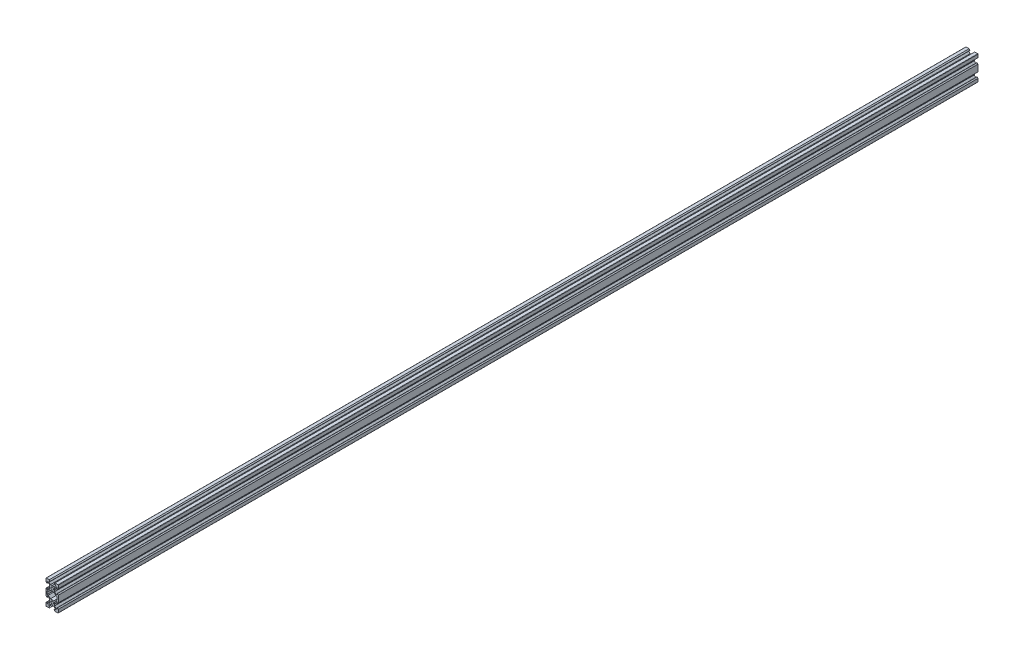
from build123d import *

# Parameters (mm, degrees)
SKETCH1_R           = 2.1
BOSS_EXTRUDE1_DEPTH = 1500


with BuildPart() as part:
    # Sketch1 → Boss-Extrude1 (new body)
    with BuildSketch(Plane.XY):
        with BuildLine():
            Line((4.58, -20), (9.5, -20))
            ThreePointArc((9.5, -20), (9.853553391, -19.853553391), (10, -19.5))
            Line((10, -19.5), (10, -14.58))
            Line((10, -14.58), (8.545, -13.125))
            Line((8.545, -13.125), (8.2, -13.125))
            Line((8.2, -13.125), (8.2, -15.5))
            Line((8.2, -15.5), (6.560660172, -15.5))
            Line((6.560660172, -15.5), (3.9, -12.839339828))
            Line((3.9, -12.839339828), (3.9, -10.21))
            Line((3.9, -10.21), (3.69, -10))
            Line((3.69, -10), (3.9, -9.79))
            Line((3.9, -9.79), (3.9, -7.160660172))
            Line((3.9, -7.160660172), (6.560660172, -4.5))
            Line((6.560660172, -4.5), (8.2, -4.5))
            Line((8.2, -4.5), (8.2, -6.875))
            Line((8.2, -6.875), (8.545, -6.875))
            Line((8.545, -6.875), (10, -5.42))
            Line((10, -5.42), (10, 5.42))
            Line((10, 5.42), (8.545, 6.875))
            Line((8.545, 6.875), (8.2, 6.875))
            Line((8.2, 6.875), (8.2, 4.5))
            Line((8.2, 4.5), (6.560660172, 4.5))
            Line((6.560660172, 4.5), (3.9, 7.160660172))
            Line((3.9, 7.160660172), (3.9, 9.79))
            Line((3.9, 9.79), (3.69, 10))
            Line((3.69, 10), (3.9, 10.21))
            Line((3.9, 10.21), (3.9, 12.839339828))
            Line((3.9, 12.839339828), (6.560660172, 15.5))
            Line((6.560660172, 15.5), (8.2, 15.5))
            Line((8.2, 15.5), (8.2, 13.125))
            Line((8.2, 13.125), (8.545, 13.125))
            Line((8.545, 13.125), (10, 14.58))
            Line((10, 14.58), (10, 19.5))
            ThreePointArc((10, 19.5), (9.853553391, 19.853553391), (9.5, 20))
            Line((9.5, 20), (4.58, 20))
            Line((4.58, 20), (3.125, 18.545))
            Line((3.125, 18.545), (3.125, 18.2))
            Line((3.125, 18.2), (5.5, 18.2))
            Line((5.5, 18.2), (5.5, 16.560660172))
            Line((5.5, 16.560660172), (2.839339828, 13.9))
            Line((2.839339828, 13.9), (0.21, 13.9))
            Line((0.21, 13.9), (0, 13.69))
            Line((0, 13.69), (-0.21, 13.9))
            Line((-0.21, 13.9), (-2.839339828, 13.9))
            Line((-2.839339828, 13.9), (-5.5, 16.560660172))
            Line((-5.5, 16.560660172), (-5.5, 18.2))
            Line((-5.5, 18.2), (-3.125, 18.2))
            Line((-3.125, 18.2), (-3.125, 18.545))
            Line((-3.125, 18.545), (-4.58, 20))
            Line((-4.58, 20), (-9.5, 20))
            ThreePointArc((-9.5, 20), (-9.853553391, 19.853553391), (-10, 19.5))
            Line((-10, 19.5), (-10, 14.58))
            Line((-10, 14.58), (-8.545, 13.125))
            Line((-8.545, 13.125), (-8.2, 13.125))
            Line((-8.2, 13.125), (-8.2, 15.5))
            Line((-8.2, 15.5), (-6.560660172, 15.5))
            Line((-6.560660172, 15.5), (-3.9, 12.839339828))
            Line((-3.9, 12.839339828), (-3.9, 10.21))
            Line((-3.9, 10.21), (-3.69, 10))
            Line((-3.69, 10), (-3.9, 9.79))
            Line((-3.9, 9.79), (-3.9, 7.160660172))
            Line((-3.9, 7.160660172), (-6.560660172, 4.5))
            Line((-6.560660172, 4.5), (-8.2, 4.5))
            Line((-8.2, 4.5), (-8.2, 6.875))
            Line((-8.2, 6.875), (-8.545, 6.875))
            Line((-8.545, 6.875), (-10, 5.42))
            Line((-10, 5.42), (-10, -5.42))
            Line((-10, -5.42), (-8.545, -6.875))
            Line((-8.545, -6.875), (-8.2, -6.875))
            Line((-8.2, -6.875), (-8.2, -4.5))
            Line((-8.2, -4.5), (-6.560660172, -4.5))
            Line((-6.560660172, -4.5), (-3.9, -7.160660172))
            Line((-3.9, -7.160660172), (-3.9, -9.79))
            Line((-3.9, -9.79), (-3.69, -10))
            Line((-3.69, -10), (-3.9, -10.21))
            Line((-3.9, -10.21), (-3.9, -12.839339828))
            Line((-3.9, -12.839339828), (-6.560660172, -15.5))
            Line((-6.560660172, -15.5), (-8.2, -15.5))
            Line((-8.2, -15.5), (-8.2, -13.125))
            Line((-8.2, -13.125), (-8.545, -13.125))
            Line((-8.545, -13.125), (-10, -14.58))
            Line((-10, -14.58), (-10, -19.5))
            ThreePointArc((-10, -19.5), (-9.853553391, -19.853553391), (-9.5, -20))
            Line((-9.5, -20), (-4.58, -20))
            Line((-4.58, -20), (-3.125, -18.545))
            Line((-3.125, -18.545), (-3.125, -18.2))
            Line((-3.125, -18.2), (-5.5, -18.2))
            Line((-5.5, -18.2), (-5.5, -16.560660172))
            Line((-5.5, -16.560660172), (-2.839339828, -13.9))
            Line((-2.839339828, -13.9), (-0.21, -13.9))
            Line((-0.21, -13.9), (0, -13.69))
            Line((0, -13.69), (0.21, -13.9))
            Line((0.21, -13.9), (2.839339828, -13.9))
            Line((2.839339828, -13.9), (5.5, -16.560660172))
            Line((5.5, -16.560660172), (5.5, -18.2))
            Line((5.5, -18.2), (3.125, -18.2))
            Line((3.125, -18.2), (3.125, -18.545))
            Line((3.125, -18.545), (4.58, -20))
        make_face()
        with Locations((0, -10)):
            Circle(SKETCH1_R, mode=Mode.SUBTRACT)
        Polygon((-6.239339828, -2.7), (-8.2, -2.7), (-8.2, 2.7), (-6.239339828, 2.7), (-2.839339828, 6.1), (2.839339828, 6.1), (6.239339828, 2.7), (8.2, 2.7), (8.2, -2.7), (6.239339828, -2.7), (2.839339828, -6.1), (-2.839339828, -6.1), align=None, mode=Mode.SUBTRACT)
        with Locations((0, 10)):
            Circle(SKETCH1_R, mode=Mode.SUBTRACT)
    extrude(amount=BOSS_EXTRUDE1_DEPTH)


solid = part.part
